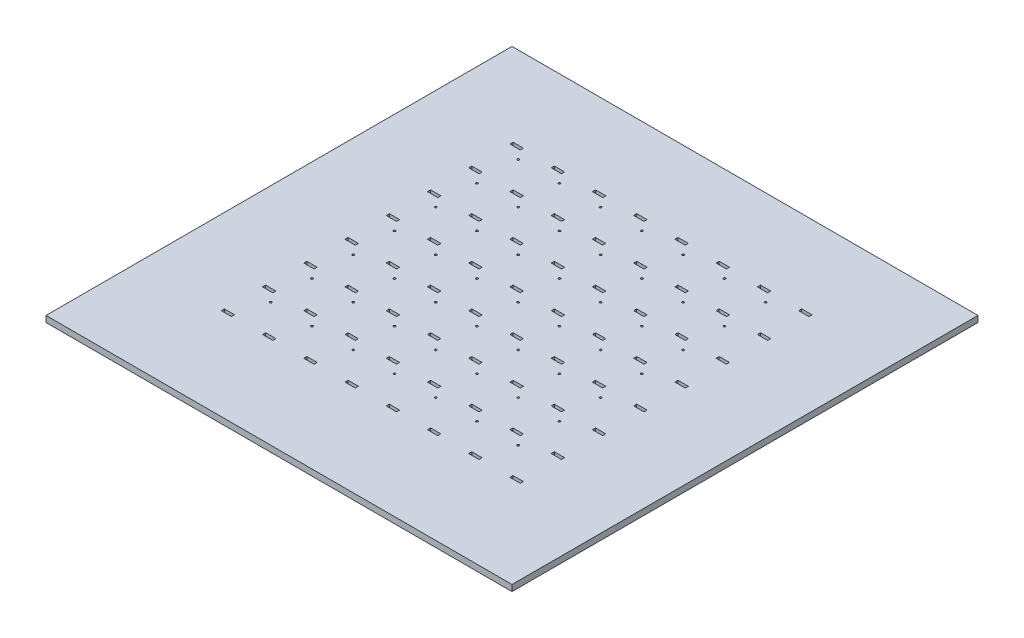
from build123d import *

# Parameters (mm, degrees)
ESQUISSE2_W                     = 226
ESQUISSE2_H                     = 226
BOSS_EXTRU_1_DEPTH              = 3
ESQUISSE6_W                     = 5
ESQUISSE6_H                     = 1.5
ENL_V_MAT_EXTRU_1_DEPTH         = 5
R_P_TITION_LIN_AIRE2_COUNT      = 8
R_P_TITION_LIN_AIRE2_PITCH      = 20
R_P_TITION_LIN_AIRE2_COUNT_DIR2 = 8
R_P_TITION_LIN_AIRE2_PITCH_DIR2 = 20
ESQUISSE8_R                     = 0.5
ENL_V_MAT_EXTRU_2_DEPTH         = 5
R_P_TITION_LIN_AIRE3_COUNT      = 7
R_P_TITION_LIN_AIRE3_PITCH      = 20
R_P_TITION_LIN_AIRE3_COUNT_DIR2 = 7
R_P_TITION_LIN_AIRE3_PITCH_DIR2 = 20


with BuildPart() as part:
    # Esquisse2 → Boss.-Extru.1 (new body)
    with BuildSketch(Plane(origin=(0, 0, 0), x_dir=(1, 0, 0), z_dir=(0, 1, 0))):
        with Locations((113, 113)):
            Rectangle(ESQUISSE2_W, ESQUISSE2_H)
    extrude(amount=BOSS_EXTRU_1_DEPTH)

    # Esquisse6 → Enlèv. mat.-Extru.1 (cut)
    with BuildSketch(Plane(origin=(0, 3, 0), x_dir=(1, 0, 0), z_dir=(0, 1, 0))):
        with Locations((43, 185.25)):
            Rectangle(ESQUISSE6_W, ESQUISSE6_H)
    enl_v_mat_extru_1 = extrude(amount=-ENL_V_MAT_EXTRU_1_DEPTH, mode=Mode.SUBTRACT)

    # Répétition linéaire2: Enl_v. mat.-Extru.1 8 × 8
    with Locations(*[(j * R_P_TITION_LIN_AIRE2_PITCH_DIR2, 0, i * R_P_TITION_LIN_AIRE2_PITCH) for i in range(R_P_TITION_LIN_AIRE2_COUNT) for j in range(R_P_TITION_LIN_AIRE2_COUNT_DIR2) if (i, j) != (0, 0)]):
        add(enl_v_mat_extru_1, mode=Mode.SUBTRACT)

    # Esquisse8 → Enlèv. mat.-Extru.2 (cut)
    with BuildSketch(Plane(origin=(0, 3, 0), x_dir=(1, 0, 0), z_dir=(0, 1, 0))):
        with Locations(Location((49, 180, 0), (0, 0, 270))):  # turned: the seam where the file's is
            Circle(ESQUISSE8_R)
    enl_v_mat_extru_2 = extrude(amount=-ENL_V_MAT_EXTRU_2_DEPTH, mode=Mode.SUBTRACT)

    # Répétition linéaire3: Enl_v. mat.-Extru.2 7 × 7
    with Locations(*[(j * R_P_TITION_LIN_AIRE3_PITCH_DIR2, 0, i * R_P_TITION_LIN_AIRE3_PITCH) for i in range(R_P_TITION_LIN_AIRE3_COUNT) for j in range(R_P_TITION_LIN_AIRE3_COUNT_DIR2) if (i, j) != (0, 0)]):
        add(enl_v_mat_extru_2, mode=Mode.SUBTRACT)


solid = part.part
